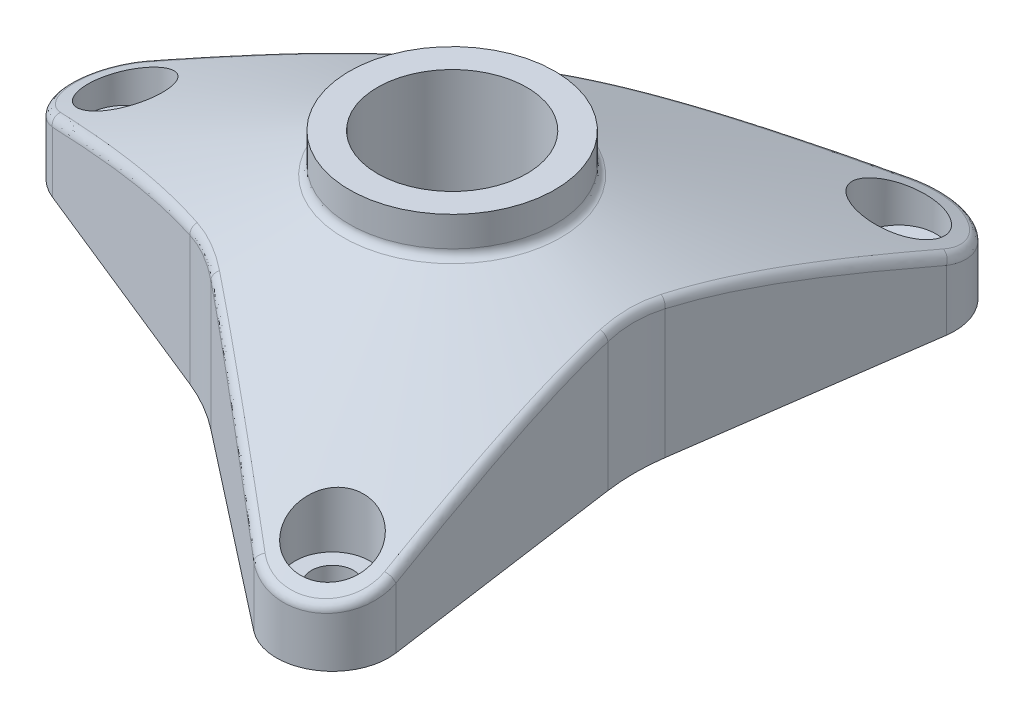
from build123d import *

# Parameters (mm, degrees)
BOSS_EXTRUDE1_DEPTH = 22
SKETCH3_R           = 8
CUT_EXTRUDE1_DEPTH  = 23.0000001
FILLET1_R           = 22
SKETCH4_R           = 2.25
CUT_EXTRUDE2_DEPTH  = 4
CIRPATTERN1_COUNT   = 3
SKETCH5_R           = 4
CUT_EXTRUDE3_DEPTH  = 16
CIRPATTERN2_COUNT   = 3
FILLET2_R           = 1


with BuildPart() as part:
    # Sketch1 → Boss-Extrude1 (new body)
    with BuildSketch(Plane(origin=(0, 0, 0), x_dir=(1, 0, 0), z_dir=(0, 1, 0))):
        with BuildLine():
            Line((-37.24763956, 5.563103127), (-9.649523888, 16.713465643))
            Line((-9.649523888, 16.713465643), (13.806031148, 35.038953654))
            ThreePointArc((13.806031148, 35.038953654), (20.5, 35.507041555), (23.441608412, 29.475850527))
            Line((23.441608412, 29.475850527), (19.299047776, 0))
            Line((19.299047776, 0), (23.441608412, -29.475850527))
            ThreePointArc((23.441608412, -29.475850527), (20.5, -35.507041555), (13.806031148, -35.038953654))
            Line((13.806031148, -35.038953654), (-9.649523888, -16.713465643))
            Line((-9.649523888, -16.713465643), (-37.24763956, -5.563103127))
            ThreePointArc((-37.24763956, -5.563103127), (-41, 0), (-37.24763956, 5.563103127))
        make_face()
    extrude(amount=BOSS_EXTRUDE1_DEPTH)

    # Sketch2 → Cut-Revolve1 (revolve, cut)
    with BuildSketch(Plane.XY, mode=Mode.PRIVATE) as cut_revolve1_sk:
        Polygon((0, 22), (-11, 22), (-11, 18.120786775), (-41, 6), (-41, 33.073701739), (0, 33.073701739), align=None)
    revolve(cut_revolve1_sk.sketch.rotate(Axis((0, 0, 0), (0, 1, 0)), 270), axis=Axis((0, 0, 0), (0, 1, 0)), mode=Mode.SUBTRACT)  # turned: the seam where the file's is

    # Sketch3 → Cut-Extrude1 (cut, through all)
    with BuildSketch(Plane(origin=(0, 22, 0), x_dir=(1, 0, 0), z_dir=(0, 1, 0))):
        with Locations(Location((0, 0, 0), (0, 0, 270))):  # turned: the seam where the file's is
            Circle(SKETCH3_R)
    extrude(amount=-CUT_EXTRUDE1_DEPTH, mode=Mode.SUBTRACT)

    # Fillet1
    fillet1_edges = [part.edges().sort_by_distance(p)[0] for p in [
        (19.299047776, 7.383876912, 0),
        (-9.649523888, 7.383876912, -16.713465643),
        (-9.649523888, 7.383876912, 16.713465643),
    ]]
    fillet(fillet1_edges, radius=FILLET1_R)

    # Sketch4 → Cut-Extrude2 (cut)
    with BuildSketch(Plane.XZ):
        with Locations(Location((-35, 0, 0), (0, 0, 270))):  # turned: the seam where the file's is
            Circle(SKETCH4_R)
    cut_extrude2 = extrude(amount=-CUT_EXTRUDE2_DEPTH, mode=Mode.SUBTRACT)

    # CirPattern1: Cut-Extrude2 ×3 about axis
    cirpattern1_axis = Axis((0, 0, 0), (0, 1, 0))
    for i in range(1, CIRPATTERN1_COUNT):
        add(cut_extrude2.rotate(cirpattern1_axis, i * 360 / CIRPATTERN1_COUNT), mode=Mode.SUBTRACT)

    # Sketch5 → Cut-Extrude3 (cut)
    with BuildSketch(Plane.XZ.offset(-4)):
        with Locations(Location((-35, 0, 0), (0, 0, 270))):  # turned: the seam where the file's is
            Circle(SKETCH5_R)
    cut_extrude3 = extrude(amount=-CUT_EXTRUDE3_DEPTH, mode=Mode.SUBTRACT)

    # CirPattern2: Cut-Extrude3 ×3 about axis
    cirpattern2_axis = Axis((0, 0, 0), (0, 1, 0))
    for i in range(1, CIRPATTERN2_COUNT):
        add(cut_extrude3.rotate(cirpattern2_axis, i * 360 / CIRPATTERN2_COUNT), mode=Mode.SUBTRACT)

    # Fillet2
    fillet2_edges = [part.edges().sort_by_distance(p)[0] for p in [
        (-41, 6, 0),
        (20.50000002, 6, -35.507041543),
        (6.94907072, 10.248612696, -29.68170903),
        (-25.042219902, 11.59484824, 10.494412767),
        (20.5, 6, 35.507041555),
        (0, 18.120786775, 11),
        (21.609538005, 11.59484824, 16.439992219),
        (21.609538005, 11.59484824, -16.439992219),
        (-25.042219902, 11.59484824, -10.494412767),
        (3.432681897, 11.59484824, 26.934404986),
        (19.515254371, 14.68040069, 0),
        (-9.757627186, 14.68040069, -16.900706047),
        (-9.757627186, 14.68040069, 16.900706047),
    ]]
    fillet(fillet2_edges, radius=FILLET2_R)


solid = part.part
